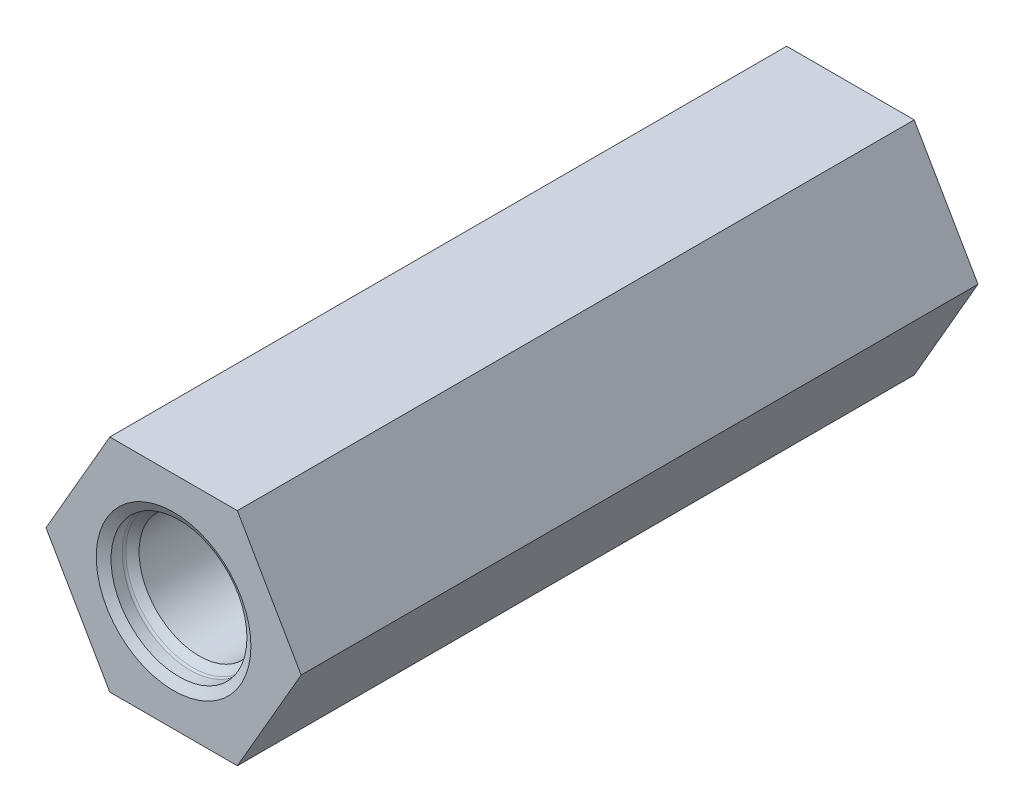
from build123d import *

# Parameters (mm, degrees)
EXTRUDE1_DEPTH     = 97.259775
SKETCH3_R          = 5.35813
CUT_EXTRUDE3_DEPTH = 98.259775
CUT_EXTRUDE2_REACH = 41.688
SKETCH4_R          = 4.2164
SKETCH5_R          = 6.3754
CUT_EXTRUDE4_DEPTH = 26.162
SKETCH6_R          = 7.14375
CUT_EXTRUDE5_DEPTH = 63.5


with BuildPart() as part:
    # Sketch1 → Extrude1 (new body)
    with BuildSketch(Plane.XY):
        Polygon((-18.330871047, 0), (-9.165435523, -15.875), (9.165435523, -15.875), (18.330871047, 0), (9.165435523, 15.875), (-9.165435523, 15.875), align=None)
    extrude(amount=EXTRUDE1_DEPTH)

    # Sketch3 → Cut-Extrude3 (cut, through all)
    with BuildSketch(Plane.XY.offset(97.259775)):
        Circle(SKETCH3_R)
    extrude(amount=-CUT_EXTRUDE3_DEPTH, mode=Mode.SUBTRACT)

    # Sketch4 → Cut-Extrude2 (cut, up to next)
    with BuildSketch(Plane(origin=(-13.748153285, -7.9375, 0), x_dir=(0, 0, 1), z_dir=(-0.866025404, -0.5, 0)), mode=Mode.PRIVATE) as cut_extrude2_sk1:
        with Locations((21.59, 0)):
            Circle(SKETCH4_R)
    cut_extrude2_tool1 = extrude(cut_extrude2_sk1.sketch, amount=-CUT_EXTRUDE2_REACH, mode=Mode.PRIVATE) & part.part
    add(cut_extrude2_tool1.solids().sort_by_distance((-13.748153, -7.9375, 21.59))[0], mode=Mode.SUBTRACT)

    # Sketch5 → Cut-Extrude4 (cut)
    with BuildSketch(Plane(origin=(0, 0, 0), x_dir=(-1, 0, 0), z_dir=(0, 0, -1))):
        Circle(SKETCH5_R)
    extrude(amount=-CUT_EXTRUDE4_DEPTH, mode=Mode.SUBTRACT)

    # Sketch6 → Cut-Extrude5 (cut)
    with BuildSketch(Plane.XY.offset(97.259775)):
        Circle(SKETCH6_R)
    extrude(amount=-CUT_EXTRUDE5_DEPTH, mode=Mode.SUBTRACT)

    # Sketch8 → Cut-Revolve1 (revolve, cut)
    with BuildSketch(Plane(origin=(0, 0, 0), x_dir=(1, 0, 0), z_dir=(0, 1, 0))):
        with BuildLine():
            Line((0, -97.259775), (0, -76.076175))
            Line((0, -76.076175), (-6.1468, -76.076175))
            Line((-6.1468, -76.076175), (-8.6614, -78.209775))
            Line((-8.6614, -78.209775), (-8.6614, -93.55685451))
            Line((-8.6614, -93.55685451), (-9.617510245, -94.512964755))
            ThreePointArc((-9.617510245, -94.512964755), (-9.727630803, -94.677771816), (-9.7663, -94.872175))
            Line((-9.7663, -94.872175), (-9.7663, -96.482546068))
            Line((-9.7663, -96.482546068), (-11.1125, -97.259775))
            Line((-11.1125, -97.259775), (0, -97.259775))
        make_face()
    revolve(axis=Axis((0, 0, 97.259775), (0, 0, -1)), mode=Mode.SUBTRACT)

    # Sketch10 → Cut-Revolve2 (revolve, cut)
    with BuildSketch(Plane(origin=(0, 0, 0), x_dir=(1, 0, 0), z_dir=(0, 1, 0))):
        with BuildLine():
            Line((0, 0), (-8.7376, 0))
            Line((-8.7376, 0), (-7.366, -0.791893629))
            Line((-7.366, -0.791893629), (-7.366, -2.1082))
            ThreePointArc((-7.366, -2.1082), (-7.327330803, -2.302603184), (-7.217210245, -2.467410245))
            Line((-7.217210245, -2.467410245), (-6.3754, -3.30922049))
            Line((-6.3754, -3.30922049), (-6.3754, -17.907))
            Line((-6.3754, -17.907), (0, -17.907))
            Line((0, -17.907), (0, 0))
        make_face()
    revolve(axis=Axis((0, 0, 0), (0, 0, -1)), mode=Mode.SUBTRACT)


solid = part.part
